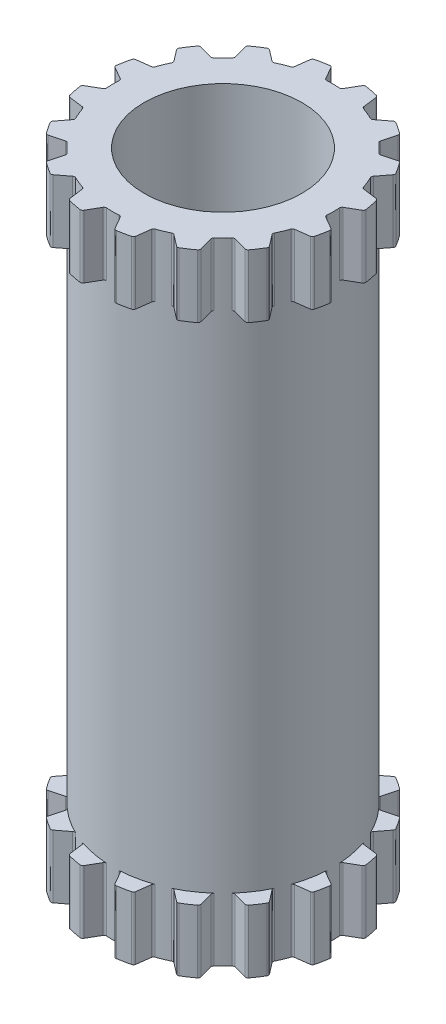
from build123d import *
from build123d.topology import SkipClean

# Parameters (mm, degrees)
BODYS_W               = 2
BODYS_H               = 10
M3X0_5_TAPPED_HOLE1_D = 2.5
MIDBODYCUTS_W         = 0.25
MIDBODYCUTS_H         = 8
GROOVECUT_DEPTH       = 6.744562647
GCCP_COUNT            = 16


with BuildPart() as part:
    # BodyS → Body (revolve)
    with BuildSketch(Plane.XY, mode=Mode.PRIVATE) as body_sk:
        with Locations((1, 0)):
            Rectangle(BODYS_W, BODYS_H)
    revolve(body_sk.sketch.rotate(Axis((0, -5, 0), (0, 1, 0)), 90), axis=Axis((0, -5, 0), (0, 1, 0)))

    # M3x0.5 Tapped Hole1 (through all)
    with Locations(Plane(origin=(0, 5, 0), x_dir=(1, 0, 0), z_dir=(0, 1, 0))):
        with Locations((0, 0)):
            Hole(M3X0_5_TAPPED_HOLE1_D / 2)

    # MidBodyCutS → MidBodyCut (revolve, cut)
    with BuildSketch(Plane.XY, mode=Mode.PRIVATE) as midbodycut_sk:
        with Locations((1.875, 0)):
            Rectangle(MIDBODYCUTS_W, MIDBODYCUTS_H)
    revolve(midbodycut_sk.sketch.rotate(Axis((0, 5.5, 0), (0, -1, 0)), 270), axis=Axis((0, 5.5, 0), (0, -1, 0)), mode=Mode.SUBTRACT)

    # GrooveCutS → GrooveCut (cut, symmetric)
    with SkipClean():  # the faces are left unmerged after this step: merging them gives an invalid solid
        with BuildSketch(Plane(origin=(0, 0, 0), x_dir=(1, 0, 0), z_dir=(0, 1, 0))):
            with BuildLine():
                Line((0.136871074, 1.767078346), (0.247975811, 1.959517396))
                ThreePointArc((0.247975811, 1.959517396), (0.265173181, 1.975513496), (0.288384518, 1.979099384))
                ThreePointArc((0.288384518, 1.979099384), (0, 2), (-0.288384518, 1.979099384))
                ThreePointArc((-0.288384518, 1.979099384), (-0.265173181, 1.975513496), (-0.247975811, 1.959517396))
                Line((-0.247975811, 1.959517396), (-0.136871074, 1.767078346))
                ThreePointArc((-0.136871074, 1.767078346), (-0.121232286, 1.751880117), (-0.099945587, 1.747143635))
                ThreePointArc((-0.099945587, 1.747143635), (0, 1.75), (0.099945587, 1.747143635))
                ThreePointArc((0.099945587, 1.747143635), (0.121232286, 1.751880117), (0.136871074, 1.767078346))
            make_face()
        groovecut = extrude(amount=GROOVECUT_DEPTH, both=True, mode=Mode.SUBTRACT)

    # GCCP: GrooveCut ×16 about axis
    with SkipClean():  # the faces are left unmerged after this step: merging them gives an invalid solid
        gccp_axis = Axis((0, 0, 0), (0, 1, 0))
        for i in range(1, GCCP_COUNT):
            add(groovecut.rotate(gccp_axis, i * 360 / GCCP_COUNT), mode=Mode.SUBTRACT)


solid = part.part
